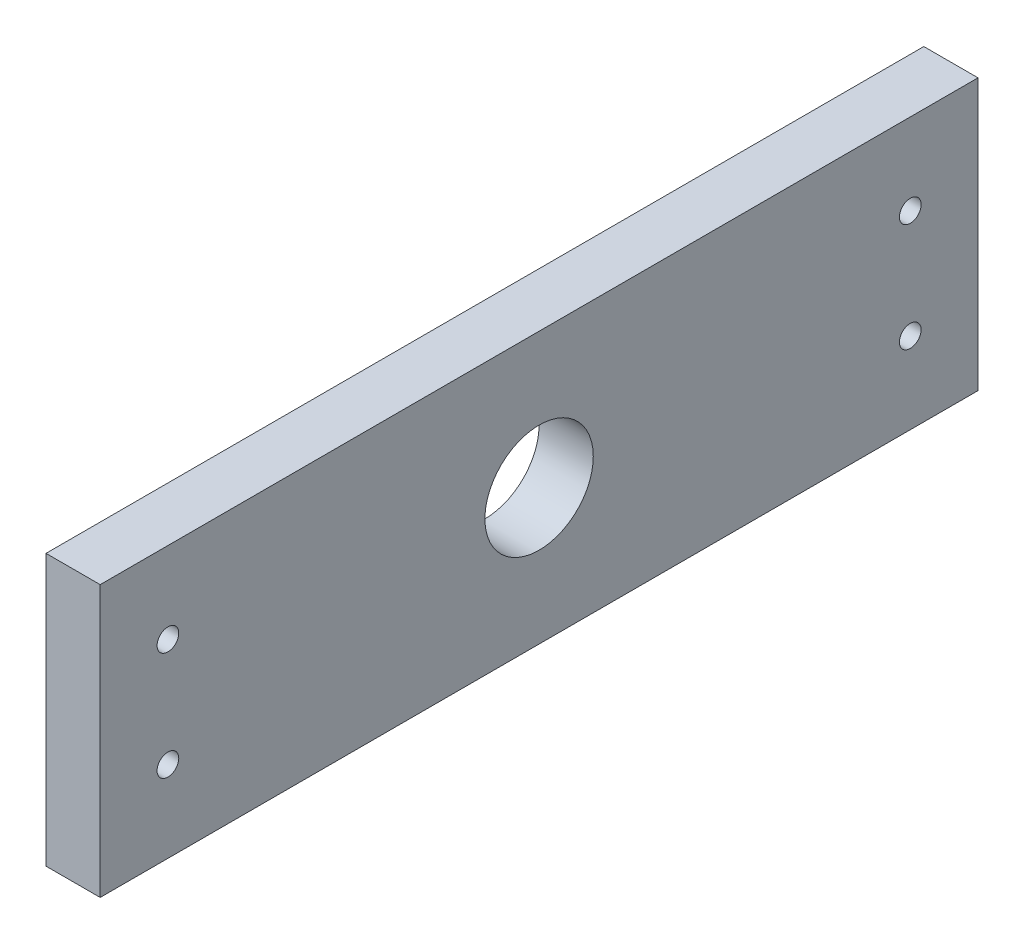
from build123d import *

# Parameters (mm, degrees)
SKETCH1_W           = 162
SKETCH1_H           = 50
SKETCH1_R           = 10
SKETCH1_R_2         = 2
BOSS_EXTRUDE1_DEPTH = 10


with BuildPart() as part:
    # Sketch1 → Boss-Extrude1 (new body)
    with BuildSketch(Plane(origin=(0, 0, 0), x_dir=(0, 0, -1), z_dir=(1, 0, 0))):
        Rectangle(SKETCH1_W, SKETCH1_H)
        Circle(SKETCH1_R, mode=Mode.SUBTRACT)
        with Locations((-68.5, 10)):
            Circle(SKETCH1_R_2, mode=Mode.SUBTRACT)
        with Locations((-68.5, -10)):
            Circle(SKETCH1_R_2, mode=Mode.SUBTRACT)
        with Locations((68.5, 10)):
            Circle(SKETCH1_R_2, mode=Mode.SUBTRACT)
        with Locations((68.5, -10)):
            Circle(SKETCH1_R_2, mode=Mode.SUBTRACT)
    extrude(amount=BOSS_EXTRUDE1_DEPTH)


solid = part.part
